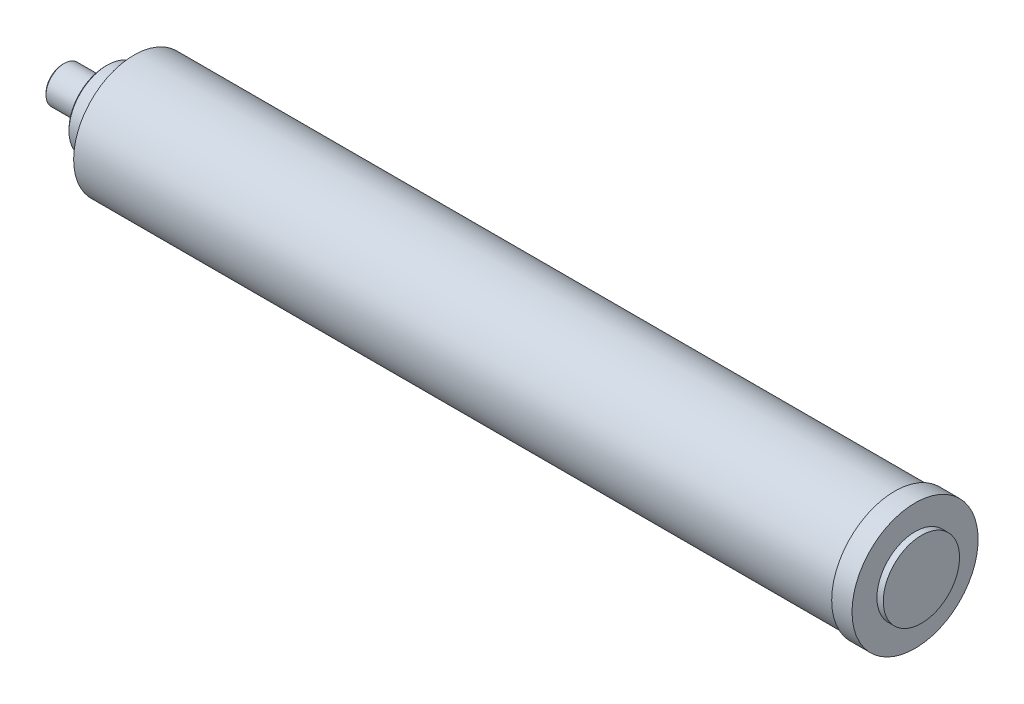
from build123d import *

# Parameters (mm, degrees)
CHANFREIN1_SIZE = 1


with BuildPart() as part:
    # Esquisse1 → Révolution1 (revolve)
    with BuildSketch(Plane.XY):
        Polygon((0, 0), (0, 11.395), (26.75, 11.395), (26.75, 23.8), (44.5, 23.8), (44.5, 37.65), (519.3, 37.65), (519.3, 39.35), (532, 39.35), (532, 23.8), (535.96, 23.8), (535.96, 0), align=None)
    revolve(axis=Axis((0, 0, 0), (1, 0, 0)))

    # Chanfrein1
    chanfrein1_edges = [part.edges().sort_by_distance(p)[0] for p in [
        (26.75, -23.8, 0),
        (0, -11.395, 0),
    ]]
    chamfer(chanfrein1_edges, length=CHANFREIN1_SIZE)


solid = part.part
